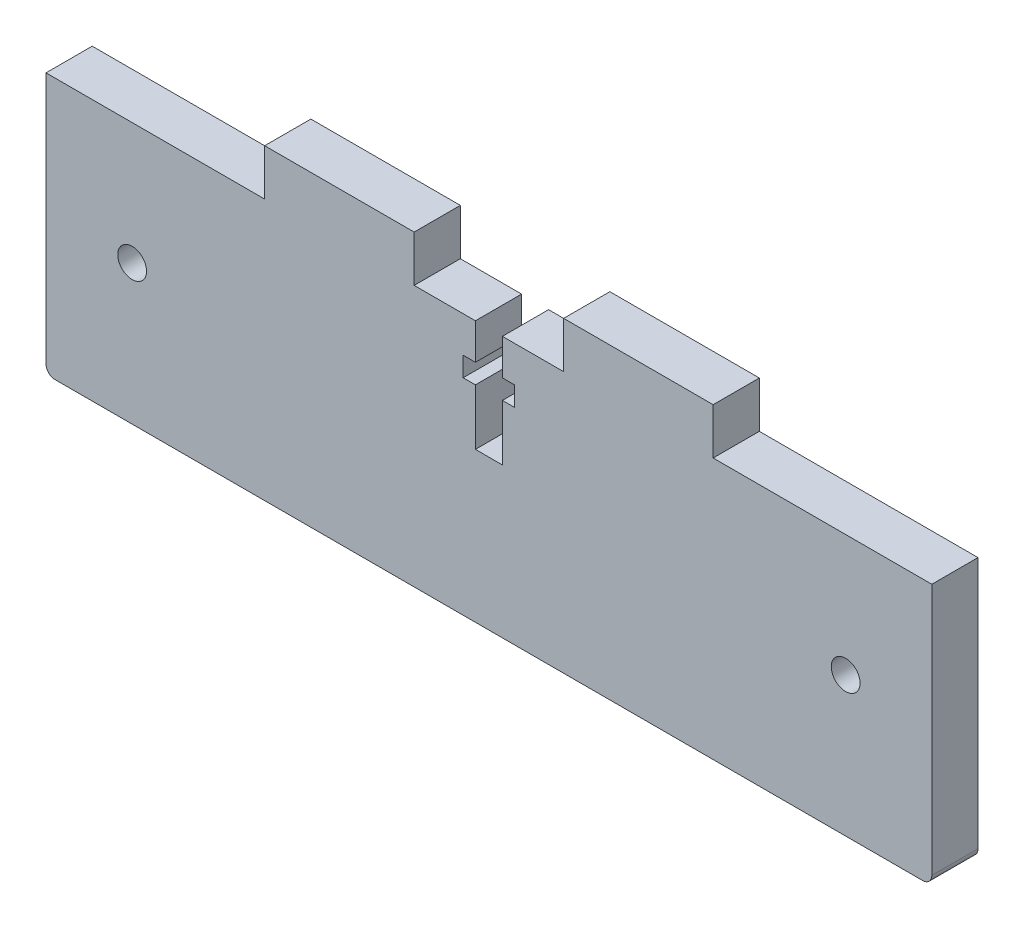
from build123d import *

# Parameters (mm, degrees)
MAIN_DEPTH               = 5.13
M3_CLEARANCE_HOLE1_D     = 3.2
M3_CLEARANCE_HOLE1_DEPTH = 5.13
SKETCH4_W                = 16.6
SKETCH4_H                = 5.13
TOP_TABS_DEPTH           = 5.13
T_SLOT_DEPTH             = 1
T_SLOT_DEPTH_BACK        = 6.13


with BuildPart() as part:
    # Sketch1 → Main (new body)
    with BuildSketch(Plane.XY):
        with BuildLine():
            Line((-54.096109727, 17.496253248), (44.263890273, 17.496253248))
            Line((44.263890273, 17.496253248), (44.263890273, -10.503746752))
            ThreePointArc((44.263890273, -10.503746752), (43.970997054, -11.210853533), (43.263890273, -11.503746752))
            Line((43.263890273, -11.503746752), (-53.096109727, -11.503746752))
            ThreePointArc((-53.096109727, -11.503746752), (-53.803216508, -11.210853533), (-54.096109727, -10.503746752))
            Line((-54.096109727, -10.503746752), (-54.096109727, 17.496253248))
        make_face()
    extrude(amount=MAIN_DEPTH)

    # M3 Clearance Hole1
    with Locations(Plane.XY.offset(5.13)):
        with Locations((-44.530109727, 3.996253248), (34.697890273, 3.996253248)):
            Hole(M3_CLEARANCE_HOLE1_D / 2, depth=M3_CLEARANCE_HOLE1_DEPTH)

    # Sketch4 → top tabs (add)
    with BuildSketch(Plane(origin=(0, 17.496253248, 0), x_dir=(1, 0, 0), z_dir=(0, 1, 0))):
        with Locations((11.683890273, -2.565)):
            Rectangle(SKETCH4_W, SKETCH4_H)
        with Locations((-21.516109727, -2.565)):
            Rectangle(SKETCH4_W, SKETCH4_H)
    extrude(amount=TOP_TABS_DEPTH)

    # Sketch5 → t-slot (cut, two sides)
    with BuildSketch(Plane.XY.offset(5.13)) as t_slot_sk:
        Polygon((-6.414608826, 144.274852992), (-6.414608826, 17.496253838), (-6.414608826, 13.501253838), (-7.773611823, 13.501254105), (-7.77361225, 11.334254105), (-6.41461225, 11.334253838), (-6.414613471, 5.127253838), (-3.417613471, 5.127253248), (-3.41761225, 11.334253248), (-2.05861225, 11.334252981), (-2.058611823, 13.501252981), (-3.417610628, 13.501253248), (-3.417610628, 17.496253248), (-3.417610628, 144.274852403), (-3.41756075, 397.832050712), (-6.414558948, 397.832051301), align=None)
    extrude(amount=T_SLOT_DEPTH, mode=Mode.SUBTRACT)
    extrude(t_slot_sk.sketch, amount=-T_SLOT_DEPTH_BACK, mode=Mode.SUBTRACT)


solid = part.part
